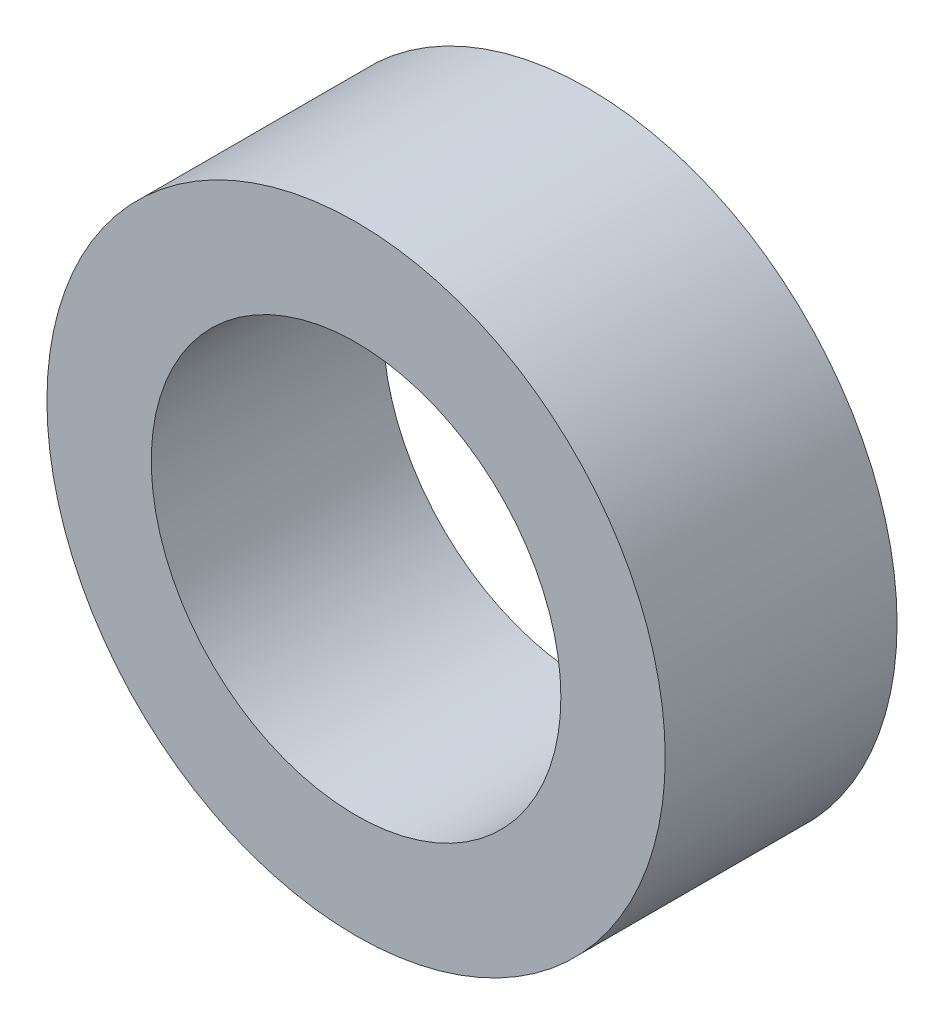
from build123d import *

# Parameters (mm, degrees)
SKETCH1_R      = 4
SKETCH1_R_2    = 2.65
EXTRUDE1_DEPTH = 1.5


with BuildPart() as part:
    # Sketch1 → Extrude1 (new body, symmetric)
    with BuildSketch(Plane.XY):
        Circle(SKETCH1_R)
        Circle(SKETCH1_R_2, mode=Mode.SUBTRACT)
    extrude(amount=EXTRUDE1_DEPTH, both=True)


solid = part.part
